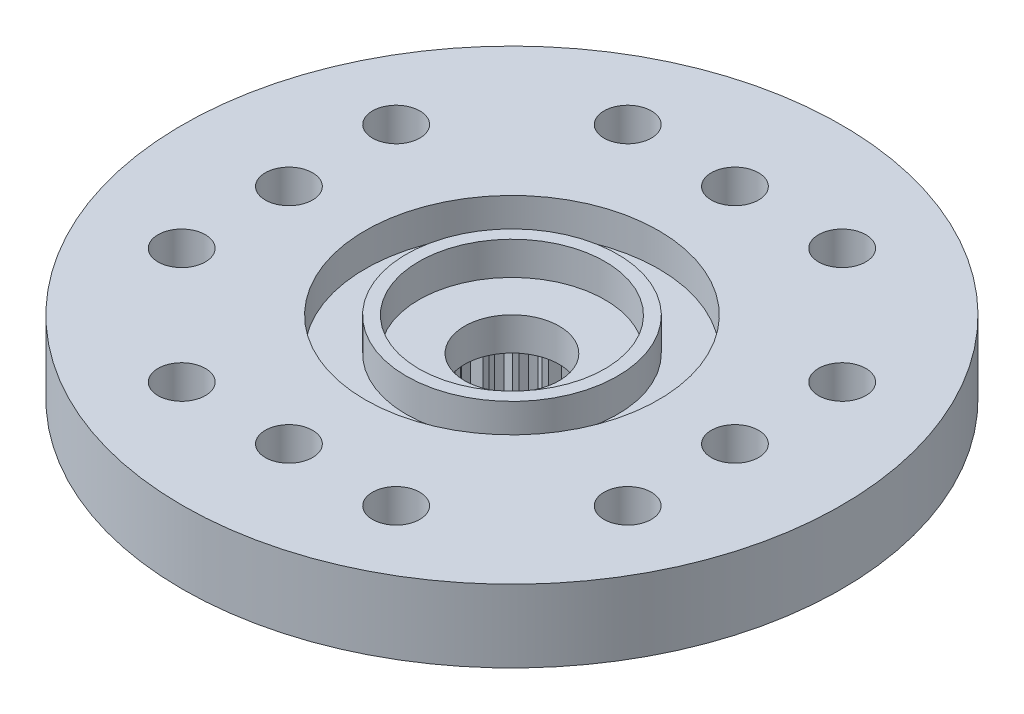
from build123d import *

# Parameters (mm, degrees)
ESQUISSE2_W                  = 4.45
ESQUISSE2_H                  = 5.6
ESQUISSE3_R                  = 10.45
ESQUISSE3_R_2                = 0.75
BOSS_EXTRU_1_DEPTH           = 2.3
ESQUISSE4_R                  = 2.95
ENL_V_MAT_EXTRU_1_DEPTH      = 1.05
ESQUISSE5_R                  = 4.65
ESQUISSE5_R_2                = 3.35
ENL_V_MAT_EXTRU_2_DEPTH      = 1.05
ESQUISSE6_R                  = 1.5
ENL_V_MAT_EXTRU_3_DEPTH      = 6.6
ESQUISSE8_R                  = 2.68
ENL_V_MAT_EXTRU_4_DEPTH      = 4.5
ENL_V_MAT_EXTRU_5_DEPTH      = 4.5
R_P_TITION_CIRCULAIRE1_COUNT = 25


with BuildPart() as part:
    # Esquisse2 → Révolution1 (revolve)
    with BuildSketch(Plane.XY):
        with Locations((-2.225, -0.7)):
            Rectangle(ESQUISSE2_W, ESQUISSE2_H)
    revolve(axis=Axis((0, 3.929571688, 0), (0, -1, 0)))

    # Esquisse3 → Boss.-Extru.1 (add)
    with BuildSketch(Plane(origin=(0, 2.1, 0), x_dir=(1, 0, 0), z_dir=(0, 1, 0))):
        Circle(ESQUISSE3_R)
        with Locations((-3.4, 7.071067812)):
            Circle(ESQUISSE3_R_2, mode=Mode.SUBTRACT)
        with Locations((0, 7.071067812)):
            Circle(ESQUISSE3_R_2, mode=Mode.SUBTRACT)
        with Locations((3.4, 7.071067812)):
            Circle(ESQUISSE3_R_2, mode=Mode.SUBTRACT)
        with Locations((-7.071067812, 3.4)):
            Circle(ESQUISSE3_R_2, mode=Mode.SUBTRACT)
        with Locations((-7.071067812, 0)):
            Circle(ESQUISSE3_R_2, mode=Mode.SUBTRACT)
        with Locations((-7.071067812, -3.4)):
            Circle(ESQUISSE3_R_2, mode=Mode.SUBTRACT)
        with Locations((-3.4, -7.071067812)):
            Circle(ESQUISSE3_R_2, mode=Mode.SUBTRACT)
        with Locations((0, -7.071067812)):
            Circle(ESQUISSE3_R_2, mode=Mode.SUBTRACT)
        with Locations((3.4, -7.071067812)):
            Circle(ESQUISSE3_R_2, mode=Mode.SUBTRACT)
        with Locations((7.071067812, 3.4)):
            Circle(ESQUISSE3_R_2, mode=Mode.SUBTRACT)
        with Locations((7.071067812, 0)):
            Circle(ESQUISSE3_R_2, mode=Mode.SUBTRACT)
        with Locations((7.071067812, -3.4)):
            Circle(ESQUISSE3_R_2, mode=Mode.SUBTRACT)
    extrude(amount=-BOSS_EXTRU_1_DEPTH)

    # Esquisse4 → Enlèv. mat.-Extru.1 (cut)
    with BuildSketch(Plane(origin=(0, 2.1, 0), x_dir=(1, 0, 0), z_dir=(0, 1, 0))):
        Circle(ESQUISSE4_R)
    extrude(amount=-ENL_V_MAT_EXTRU_1_DEPTH, mode=Mode.SUBTRACT)

    # Esquisse5 → Enlèv. mat.-Extru.2 (cut)
    with BuildSketch(Plane(origin=(0, 2.1, 0), x_dir=(1, 0, 0), z_dir=(0, 1, 0))):
        Circle(ESQUISSE5_R)
        Circle(ESQUISSE5_R_2, mode=Mode.SUBTRACT)
    extrude(amount=-ENL_V_MAT_EXTRU_2_DEPTH, mode=Mode.SUBTRACT)

    # Esquisse6 → Enlèv. mat.-Extru.3 (cut, through all)
    with BuildSketch(Plane.XZ.offset(3.5)):
        Circle(ESQUISSE6_R)
    extrude(amount=-ENL_V_MAT_EXTRU_3_DEPTH, mode=Mode.SUBTRACT)

    # Esquisse8 → Enlèv. mat.-Extru.4 (cut, through all)
    with BuildSketch(Plane(origin=(0, 0, 0), x_dir=(1, 0, 0), z_dir=(0, 1, 0))):
        Circle(ESQUISSE8_R)
    extrude(amount=-ENL_V_MAT_EXTRU_4_DEPTH, mode=Mode.SUBTRACT)

    # Esquisse9 → Enlèv. mat.-Extru.5 (cut, through all)
    with BuildSketch(Plane(origin=(0, 0, 0), x_dir=(1, 0, 0), z_dir=(0, 1, 0))):
        with BuildLine():
            Line((0.10528472, -3.048182266), (0.265600366, -2.666806413))
            ThreePointArc((0.265600366, -2.666806413), (0, -2.68), (-0.265600366, -2.666806413))
            Line((-0.265600366, -2.666806413), (-0.10528472, -3.048182266))
            ThreePointArc((-0.10528472, -3.048182266), (0, -3.05), (0.10528472, -3.048182266))
        make_face()
    enl_v_mat_extru_5 = extrude(amount=-ENL_V_MAT_EXTRU_5_DEPTH, mode=Mode.SUBTRACT)

    # Répétition circulaire1: Enlèv. mat.-Extru.5 ×25 about axis
    r_p_tition_circulaire1_axis = Axis((0, 0, 0), (0, 1, 0))
    for i in range(1, R_P_TITION_CIRCULAIRE1_COUNT):
        add(enl_v_mat_extru_5.rotate(r_p_tition_circulaire1_axis, i * 360 / R_P_TITION_CIRCULAIRE1_COUNT), mode=Mode.SUBTRACT)


solid = part.part
